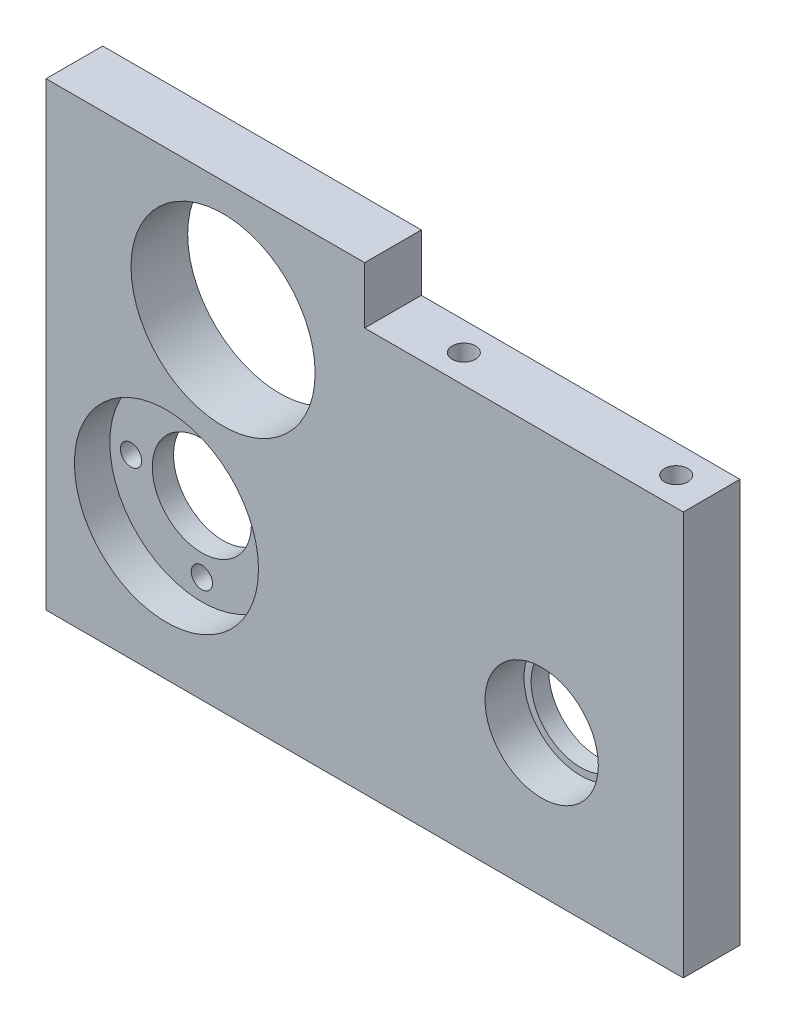
from build123d import *

# Parameters (mm, degrees)
ESQUISSE1_W             = 90
ESQUISSE1_H             = 65
ESQUISSE1_R             = 7
ESQUISSE1_R_2           = 13
BOSS_EXTRU_1_DEPTH      = 8
ESQUISSE2_R             = 13
BOSS_EXTRU_2_DEPTH      = 3
ESQUISSE3_R             = 7
ESQUISSE3_R_2           = 1.5
ENL_V_MAT_EXTRU_1_DEPTH = 4
ESQUISSE4_R             = 8
ENL_V_MAT_EXTRU_2_DEPTH = 5.5
ESQUISSE5_W             = 45
ESQUISSE5_H             = 8
ENL_V_MAT_EXTRU_3_DEPTH = 9
ESQUISSE6_R             = 1.65
ENL_V_MAT_EXTRU_4_DEPTH = 10
ESQUISSE7_R             = 1.65
ENL_V_MAT_EXTRU_5_DEPTH = 10


with BuildPart() as part:
    # Esquisse1 → Boss.-Extru.1 (new body)
    with BuildSketch(Plane.XY):
        with Locations((45, 32.5)):
            Rectangle(ESQUISSE1_W, ESQUISSE1_H)
        with Locations((70, 20)):
            Circle(ESQUISSE1_R, mode=Mode.SUBTRACT)
        with Locations((17, 20)):
            Circle(ESQUISSE1_R_2, mode=Mode.SUBTRACT)
        with Locations((25, 48)):
            Circle(ESQUISSE1_R_2, mode=Mode.SUBTRACT)
    extrude(amount=BOSS_EXTRU_1_DEPTH)

    # Esquisse2 → Boss.-Extru.2 (add)
    with BuildSketch(Plane(origin=(0, 0, 0), x_dir=(-1, 0, 0), z_dir=(0, 0, -1))):
        with Locations((-17, 20)):
            Circle(ESQUISSE2_R)
    extrude(amount=-BOSS_EXTRU_2_DEPTH)

    # Esquisse3 → Enlèv. mat.-Extru.1 (cut, through all)
    with BuildSketch(Plane.XY.offset(3)):
        with Locations((17, 20)):
            Circle(ESQUISSE3_R)
        with Locations((27, 20)):
            Circle(ESQUISSE3_R_2)
        with Locations((17, 10)):
            Circle(ESQUISSE3_R_2)
        with Locations((7, 20)):
            Circle(ESQUISSE3_R_2)
        with Locations((17, 30)):
            Circle(ESQUISSE3_R_2)
    extrude(amount=-ENL_V_MAT_EXTRU_1_DEPTH, mode=Mode.SUBTRACT)

    # Esquisse4 → Enlèv. mat.-Extru.2 (cut)
    with BuildSketch(Plane.XY.offset(8)):
        with Locations((70, 20)):
            Circle(ESQUISSE4_R)
    extrude(amount=-ENL_V_MAT_EXTRU_2_DEPTH, mode=Mode.SUBTRACT)

    # Esquisse5 → Enlèv. mat.-Extru.3 (cut, through all)
    with BuildSketch(Plane.XY.offset(8)):
        with Locations((67.5, 61)):
            Rectangle(ESQUISSE5_W, ESQUISSE5_H)
    extrude(amount=-ENL_V_MAT_EXTRU_3_DEPTH, mode=Mode.SUBTRACT)

    # Esquisse6 → Enlèv. mat.-Extru.4 (cut)
    with BuildSketch(Plane.ZY):
        with Locations((4, 7)):
            Circle(ESQUISSE6_R)
        with Locations((4, 45)):
            Circle(ESQUISSE6_R)
    extrude(amount=-ENL_V_MAT_EXTRU_4_DEPTH, mode=Mode.SUBTRACT)

    # Esquisse7 → Enlèv. mat.-Extru.5 (cut)
    with BuildSketch(Plane(origin=(0, 57, 0), x_dir=(1, 0, 0), z_dir=(0, 1, 0))):
        with Locations((85, -4)):
            Circle(ESQUISSE7_R)
        with Locations((55, -4)):
            Circle(ESQUISSE7_R)
    extrude(amount=-ENL_V_MAT_EXTRU_5_DEPTH, mode=Mode.SUBTRACT)


solid = part.part
